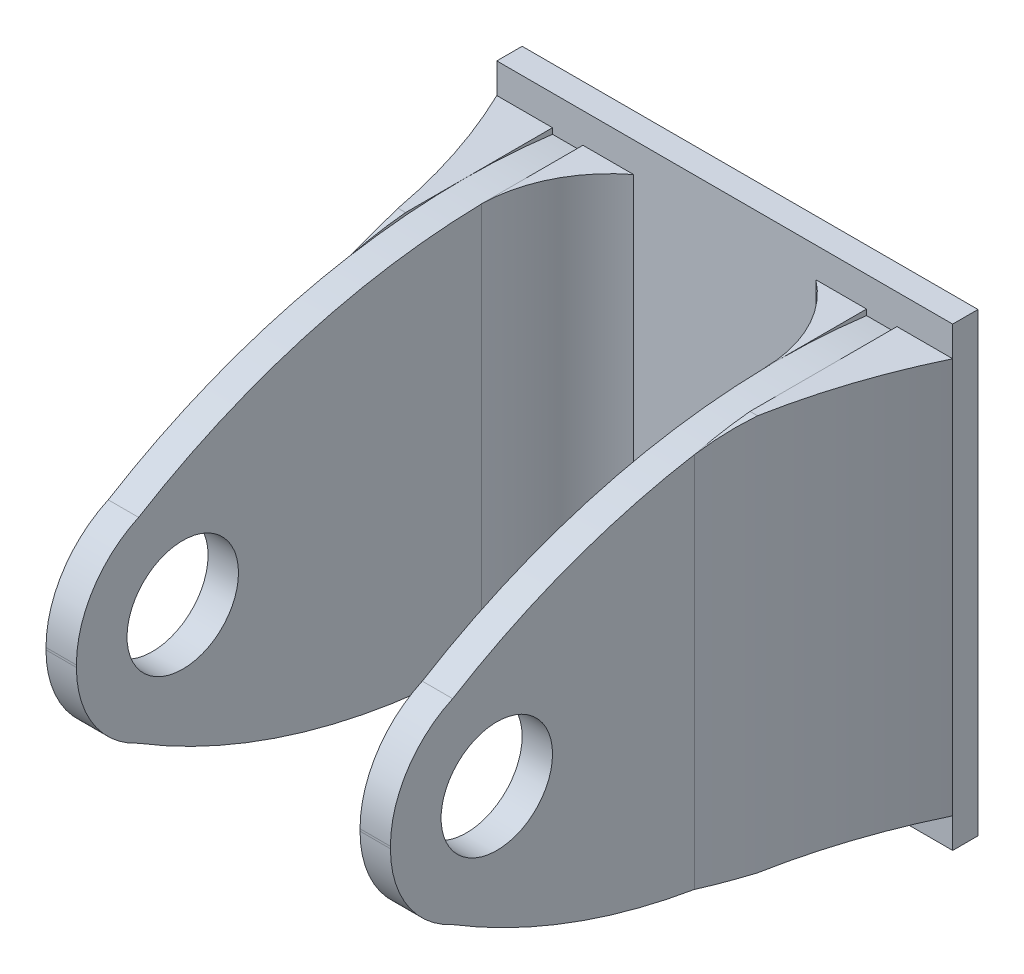
from build123d import *

# Parameters (mm, degrees)
SKETCH_1_W          = 45
SKETCH_1_H          = 45
EXTRUDE_1_DEPTH     = 2.5
EXTRUDE_2_DEPTH     = 50
SKETCH_3_R          = 5.5
CUT_EXTRUDE_1_DEPTH = 40.5
CUT_EXTRUDE_2_DEPTH = 40.5
SKETCH_5_W          = 5
SKETCH_5_H          = 39.075696326
EXTRUDE_3_DEPTH     = 10
CUT_EXTRUDE_3_DEPTH = 43.037848163
SKETCH_7_W          = 5.5
SKETCH_7_H          = 39.075696326
EXTRUDE_4_DEPTH     = 20
CUT_EXTRUDE_4_DEPTH = 46
CUT_EXTRUDE_5_DEPTH = 43.037848163


with BuildPart() as part:
    # 草图1 → 凸台-拉伸1 (new body)
    with BuildSketch(Plane.XY):
        with Locations((22.5, 22.5)):
            Rectangle(SKETCH_1_W, SKETCH_1_H)
    extrude(amount=EXTRUDE_1_DEPTH)

    # 草图2 → 凸台-拉伸2 (add)
    with BuildSketch(Plane.XY.offset(2.5)):
        Polygon((36.5, 22.5), (36.5, 0), (39.5, 0), (39.5, 45), (36.5, 45), align=None)
        Polygon((8.5, 45), (8.5, 22.5), (8.5, 0), (5.5, 0), (5.5, 45), align=None)
    extrude(amount=EXTRUDE_2_DEPTH)

    # 草图3 → 切除-拉伸1 (cut, through all)
    with BuildSketch(Plane(origin=(39.5, 0, 0), x_dir=(0, 0, -1), z_dir=(1, 0, 0))):
        with Locations((-42, 22.5)):
            Circle(SKETCH_3_R)
    extrude(amount=-CUT_EXTRUDE_1_DEPTH, mode=Mode.SUBTRACT)

    # 草图4 → 切除-拉伸2 (cut, through all)
    with BuildSketch(Plane(origin=(39.5, 0, 0), x_dir=(0, 0, -1), z_dir=(1, 0, 0))):
        with BuildLine():
            Line((-2.5, 45), (-2.5, 41.474247654))
            ThreePointArc((-2.5, 41.474247654), (-25.225749209, 40.564939101), (-46.358725725, 32.157571933))
            ThreePointArc((-46.358725725, 32.157571933), (-50.832231318, 28.283182945), (-52.5, 22.605006306))
            Line((-52.5, 22.605006306), (-52.5, 45))
            Line((-52.5, 45), (-2.5, 45))
        make_face()
        with BuildLine():
            Line((-52.5, 22.394993694), (-52.5, 0))
            Line((-52.5, 0), (-2.5, 0))
            Line((-2.5, 0), (-2.5, 3.525752346))
            ThreePointArc((-2.5, 3.525752346), (-25.225749209, 4.435060899), (-46.358725725, 12.842428067))
            ThreePointArc((-46.358725725, 12.842428067), (-50.832231318, 16.716817055), (-52.5, 22.394993694))
        make_face()
    extrude(amount=-CUT_EXTRUDE_2_DEPTH, mode=Mode.SUBTRACT)

    # 草图5 → 凸台-拉伸3 (add)
    with BuildSketch(Plane.XY.offset(2.5)):
        with Locations((11, 22.5)):
            Rectangle(SKETCH_5_W, SKETCH_5_H)
        with Locations((34, 22.5)):
            Rectangle(SKETCH_5_W, SKETCH_5_H)
    extrude(amount=EXTRUDE_3_DEPTH)

    # 草图6 → 切除-拉伸3 (cut, through all)
    with BuildSketch(Plane(origin=(0, 42.037848163, 0), x_dir=(1, 0, 0), z_dir=(0, 1, 0))):
        with BuildLine():
            Line((13.5, -2.5), (13.5, -12.5))
            Line((13.5, -12.5), (8.5, -12.5))
            ThreePointArc((8.5, -12.5), (9.861833326, -6.930916663), (13.5, -2.5))
        make_face()
        with BuildLine():
            Line((31.5, -2.5), (31.5, -12.5))
            Line((31.5, -12.5), (36.5, -12.5))
            ThreePointArc((36.5, -12.5), (35.138166674, -6.930916663), (31.5, -2.5))
        make_face()
    extrude(amount=-CUT_EXTRUDE_3_DEPTH, mode=Mode.SUBTRACT)

    # 草图7 → 凸台-拉伸4 (add)
    with BuildSketch(Plane.XY.offset(2.5)):
        with Locations((2.75, 22.5)):
            Rectangle(SKETCH_7_W, SKETCH_7_H)
        with Locations((42.25, 22.5)):
            Rectangle(SKETCH_7_W, SKETCH_7_H)
    extrude(amount=EXTRUDE_4_DEPTH)

    # 草图8 → 切除-拉伸4 (cut, through all)
    with BuildSketch(Plane(origin=(45, 0, 0), x_dir=(0, 0, -1), z_dir=(1, 0, 0))):
        with BuildLine():
            Line((-22.5, 41.085625399), (-22.5, 42.037848163))
            Line((-22.5, 42.037848163), (-17.008220021, 42.037848163))
            ThreePointArc((-17.008220021, 42.037848163), (-19.771631621, 41.662789638), (-22.5, 41.085625399))
        make_face()
        with BuildLine():
            Line((-22.5, 3.914374601), (-22.5, 2.962151837))
            Line((-22.5, 2.962151837), (-17.008220021, 2.962151837))
            ThreePointArc((-17.008220021, 2.962151837), (-19.771631621, 3.337210362), (-22.5, 3.914374601))
        make_face()
    extrude(amount=-CUT_EXTRUDE_4_DEPTH, mode=Mode.SUBTRACT)

    # 草图9 → 切除-拉伸5 (cut, through all)
    with BuildSketch(Plane(origin=(0, 2.962151837, 0), x_dir=(-1, 0, 0), z_dir=(0, -1, 0))):
        with BuildLine():
            Line((-39.5, -22.5), (-45, -22.5))
            Line((-45, -22.5), (-45, -2.5))
            ThreePointArc((-45, -2.5), (-41.339785895, -12.249691121), (-39.5, -22.5))
        make_face()
        with BuildLine():
            Line((-5.5, -22.5), (0, -22.5))
            Line((0, -22.5), (0, -2.5))
            ThreePointArc((0, -2.5), (-3.660214105, -12.249691121), (-5.5, -22.5))
        make_face()
    extrude(amount=-CUT_EXTRUDE_5_DEPTH, mode=Mode.SUBTRACT)


solid = part.part
